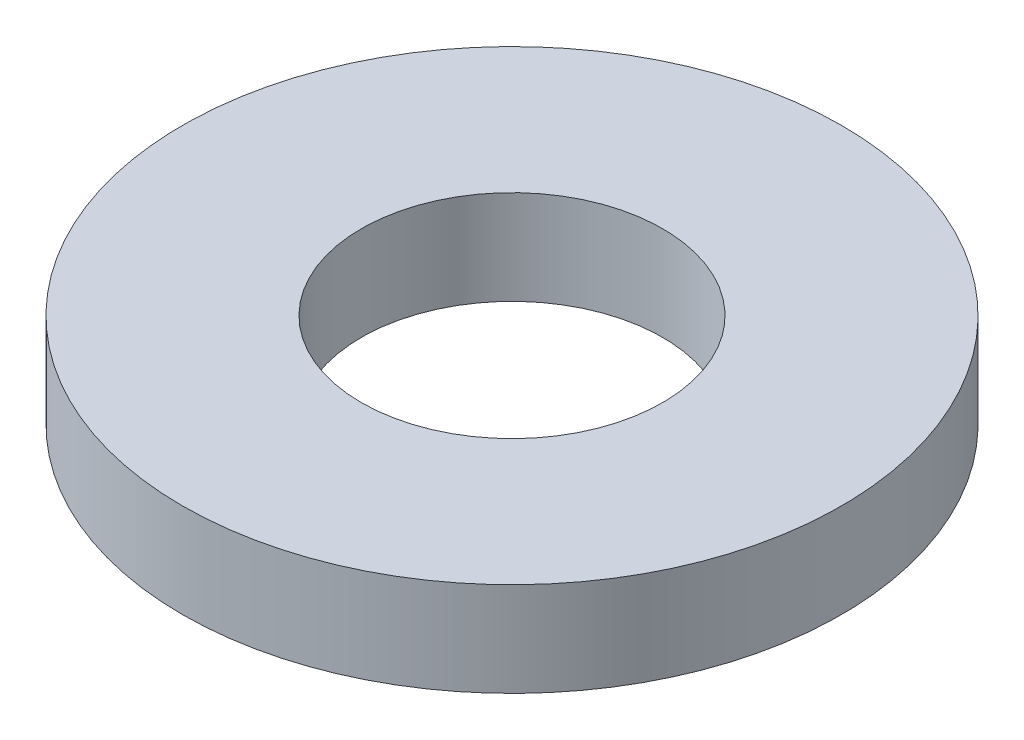
from build123d import *

# Parameters (mm, degrees)
SKETCH1_R           = 17.5
SKETCH1_R_2         = 8
BOSS_EXTRUDE1_DEPTH = 5


with BuildPart() as part:
    # Sketch1 → Boss-Extrude1 (new body)
    with BuildSketch(Plane(origin=(0, 0, 0), x_dir=(1, 0, 0), z_dir=(0, 1, 0))):
        Circle(SKETCH1_R)
        Circle(SKETCH1_R_2, mode=Mode.SUBTRACT)
    extrude(amount=BOSS_EXTRUDE1_DEPTH)


solid = part.part
